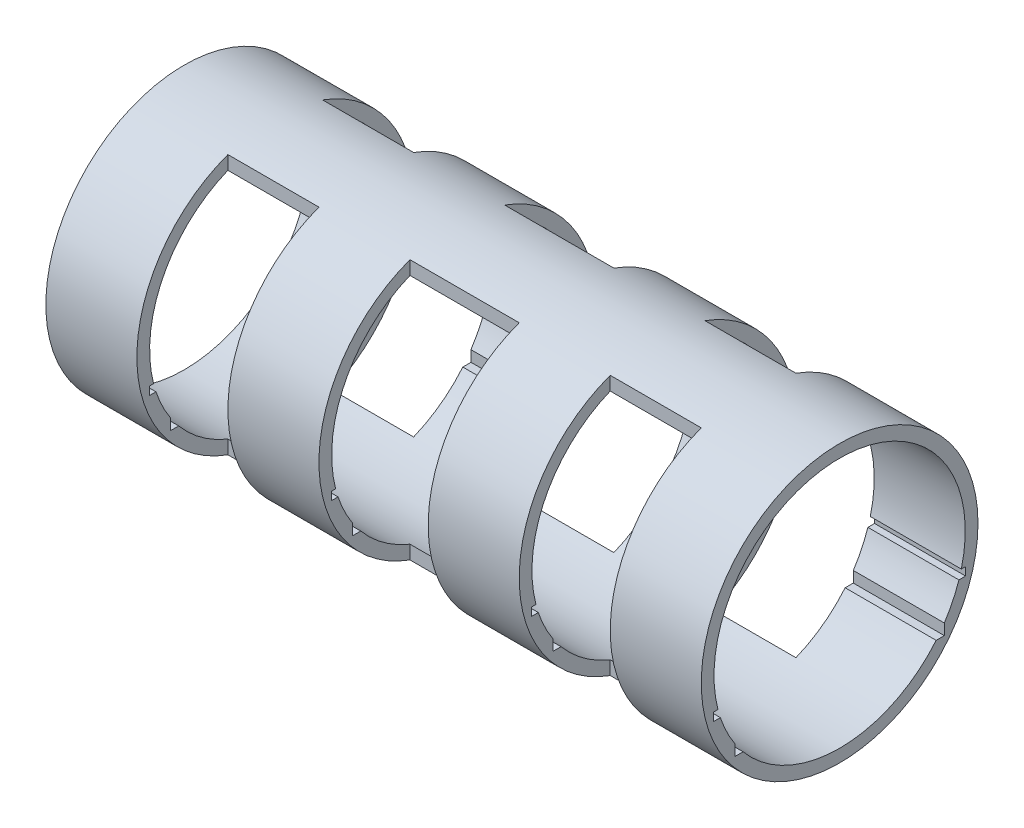
from build123d import *

# Parameters (mm, degrees)
SKETCH1_R               = 76
SKETCH1_R_2             = 69
BOSS_EXTRUDE3_DEPTH     = 360
SKETCH2_W               = 50
SKETCH2_H               = 50
SKETCH2_W_2             = 60
CUT_EXTRUDE1_DEPTH      = 125
CUT_EXTRUDE1_DEPTH_BACK = 135
SKETCH3_W               = 60
SKETCH3_H               = 50
SKETCH3_W_2             = 50
CUT_EXTRUDE3_DEPTH      = 196
CUT_EXTRUDE3_DEPTH_BACK = 244
CUT_EXTRUDE4_DEPTH      = 404


with BuildPart() as part:
    # Sketch1 → Boss-Extrude3 (new body)
    with BuildSketch(Plane(origin=(0, 0, 0), x_dir=(0, 0, -1), z_dir=(1, 0, 0))):
        Circle(SKETCH1_R)
        Circle(SKETCH1_R_2, mode=Mode.SUBTRACT)
    extrude(amount=BOSS_EXTRUDE3_DEPTH)

    # Sketch2 → Cut-Extrude1 (cut, two sides)
    with BuildSketch(Plane(origin=(0, 0, 0), x_dir=(1, 0, 0), z_dir=(0, 1, 0))) as cut_extrude1_sk:
        with Locations((75, 51)):
            Rectangle(SKETCH2_W, SKETCH2_H)
        with Locations((285, 51)):
            Rectangle(SKETCH2_W, SKETCH2_H)
        with Locations((180, 51)):
            Rectangle(SKETCH2_W_2, SKETCH2_H)
    extrude(amount=CUT_EXTRUDE1_DEPTH, mode=Mode.SUBTRACT)
    extrude(cut_extrude1_sk.sketch, amount=-CUT_EXTRUDE1_DEPTH_BACK, mode=Mode.SUBTRACT)

    # Sketch3 → Cut-Extrude3 (cut, two sides)
    with BuildSketch(Plane(origin=(0, 0, 0), x_dir=(1, 0, 0), z_dir=(0, 1, 0))) as cut_extrude3_sk:
        with Locations((180, -51)):
            Rectangle(SKETCH3_W, SKETCH3_H)
        with Locations((75, -51)):
            Rectangle(SKETCH3_W_2, SKETCH3_H)
        with Locations((285, -51)):
            Rectangle(SKETCH3_W_2, SKETCH3_H)
    extrude(amount=CUT_EXTRUDE3_DEPTH, mode=Mode.SUBTRACT)
    extrude(cut_extrude3_sk.sketch, amount=-CUT_EXTRUDE3_DEPTH_BACK, mode=Mode.SUBTRACT)

    # Sketch4 → Cut-Extrude4 (cut)
    with BuildSketch(Plane.ZY):
        with BuildLine():
            Line((-69.189205769, -21.658804332), (-65.512565168, -21.658804332))
            ThreePointArc((-65.512565168, -21.658804332), (-66.210745314, -19.420020724), (-66.832442974, -17.158804332))
            Line((-66.832442974, -17.158804332), (-69.189205769, -17.158804332))
            Line((-69.189205769, -17.158804332), (-69.189205769, -21.658804332))
        make_face()
        with BuildLine():
            Line((-57.5, -38.141185089), (-57.5, -44.158804332))
            Line((-57.5, -44.158804332), (-53.018864567, -44.158804332))
            ThreePointArc((-53.018864567, -44.158804332), (-55.341284695, -41.210947676), (-57.5, -38.141185089))
        make_face()
        with BuildLine():
            ThreePointArc((57.5, -38.141185089), (55.341284695, -41.210947676), (53.018864567, -44.158804332))
            Line((53.018864567, -44.158804332), (57.5, -44.158804332))
            Line((57.5, -44.158804332), (57.5, -38.141185089))
        make_face()
        with BuildLine():
            ThreePointArc((66.832442974, -17.158804332), (66.210745314, -19.420020724), (65.512565168, -21.658804332))
            Line((65.512565168, -21.658804332), (69.189205769, -21.658804332))
            Line((69.189205769, -21.658804332), (69.189205769, -17.158804332))
            Line((69.189205769, -17.158804332), (66.832442974, -17.158804332))
        make_face()
    extrude(amount=-CUT_EXTRUDE4_DEPTH, mode=Mode.SUBTRACT)


solid = part.part
